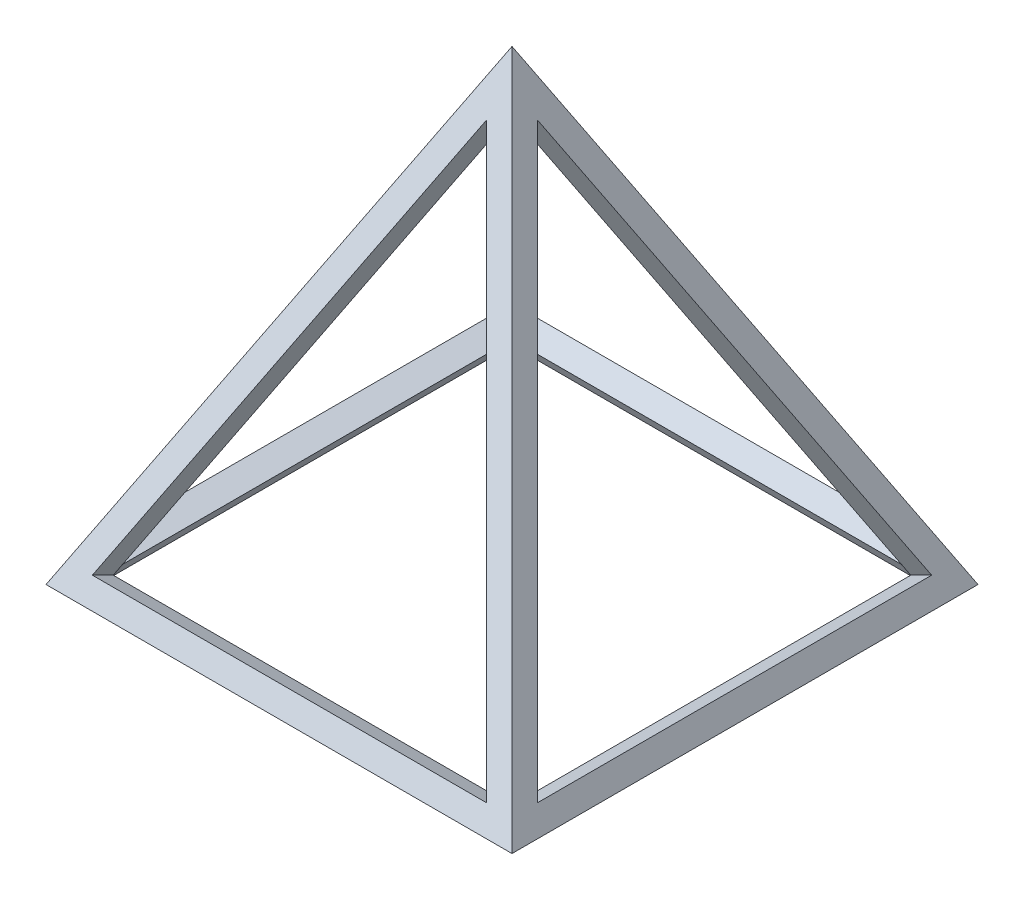
from build123d import *

# Parameters (mm, degrees)
CROQUIS1_W                 = 50
CROQUIS1_H                 = 50
SALIENTE_EXTRUIR1_DEPTH    = 50
CORTAR_EXTRUIR1_DEPTH      = 50
CORTAR_EXTRUIR2_DEPTH      = 25
CORTAR_EXTRUIR2_DEPTH_BACK = 25
VACIADO1_T                 = -2.5
CORTAR_EXTRUIR3_DEPTH      = 2.5
CORTAR_EXTRUIR4_DEPTH      = 2.5
CORTAR_EXTRUIR5_DEPTH      = 2.5
CORTAR_EXTRUIR6_DEPTH      = 2.5


with BuildPart() as part:
    # Croquis1 → Saliente-Extruir1 (new body)
    with BuildSketch(Plane(origin=(0, 0, 0), x_dir=(1, 0, 0), z_dir=(0, 1, 0))):
        Rectangle(CROQUIS1_W, CROQUIS1_H)
    extrude(amount=SALIENTE_EXTRUIR1_DEPTH)

    # Croquis2 → Cortar-Extruir1 (cut)
    with BuildSketch(Plane.ZY.offset(25)):
        Polygon((-25, 0), (0, 50), (-25, 50), align=None)
        Polygon((0, 50), (25, 0), (25, 50), align=None)
    extrude(amount=-CORTAR_EXTRUIR1_DEPTH, mode=Mode.SUBTRACT)

    # Croquis4 → Cortar-Extruir2 (cut, two sides)
    with BuildSketch(Plane(origin=(0, 0, 0), x_dir=(-1, 0, 0), z_dir=(0, 0, -1))) as cortar_extruir2_sk:
        Polygon((-25, 50), (-25, 0), (0, 50), align=None)
        Polygon((25, 50), (0, 50), (25, 0), align=None)
    extrude(amount=CORTAR_EXTRUIR2_DEPTH, mode=Mode.SUBTRACT)
    extrude(cortar_extruir2_sk.sketch, amount=-CORTAR_EXTRUIR2_DEPTH_BACK, mode=Mode.SUBTRACT)

    # Vaciado1
    vaciado1_openings = [part.faces().sort_by_distance(p)[0] for p in [
        (0, 0, 0),
    ]]
    offset(amount=VACIADO1_T, openings=vaciado1_openings, kind=Kind.INTERSECTION)

    # Croquis6 → Cortar-Extruir3 (cut)
    with BuildSketch(Plane(origin=(0, 10, -20), x_dir=(-1, 0, 0), z_dir=(0, 0.447213595, -0.894427191))):
        Polygon((0, 38.597635193), (-21.143353224, -8.680339887), (21.143353224, -8.680339887), align=None)
    extrude(amount=-CORTAR_EXTRUIR3_DEPTH, mode=Mode.SUBTRACT)

    # Croquis7 → Cortar-Extruir4 (cut)
    with BuildSketch(Plane(origin=(-20, 10, 0), x_dir=(0, 0, 1), z_dir=(-0.894427191, 0.447213595, 0))):
        Polygon((-21.143353224, -8.680339887), (21.143353224, -8.680339887), (0, 38.597635193), align=None)
    extrude(amount=-CORTAR_EXTRUIR4_DEPTH, mode=Mode.SUBTRACT)

    # Croquis8 → Cortar-Extruir5 (cut)
    with BuildSketch(Plane(origin=(0, 10, 20), x_dir=(1, 0, 0), z_dir=(0, 0.447213595, 0.894427191))):
        Polygon((-21.143353224, -8.680339887), (21.143353224, -8.680339887), (0, 38.597635193), align=None)
    extrude(amount=-CORTAR_EXTRUIR5_DEPTH, mode=Mode.SUBTRACT)

    # Croquis9 → Cortar-Extruir6 (cut)
    with BuildSketch(Plane(origin=(20, 10, 0), x_dir=(0, 0, -1), z_dir=(0.894427191, 0.447213595, 0))):
        Polygon((21.143353224, -8.680339887), (0, 38.597635193), (-21.143353224, -8.680339887), align=None)
    extrude(amount=-CORTAR_EXTRUIR6_DEPTH, mode=Mode.SUBTRACT)


solid = part.part
